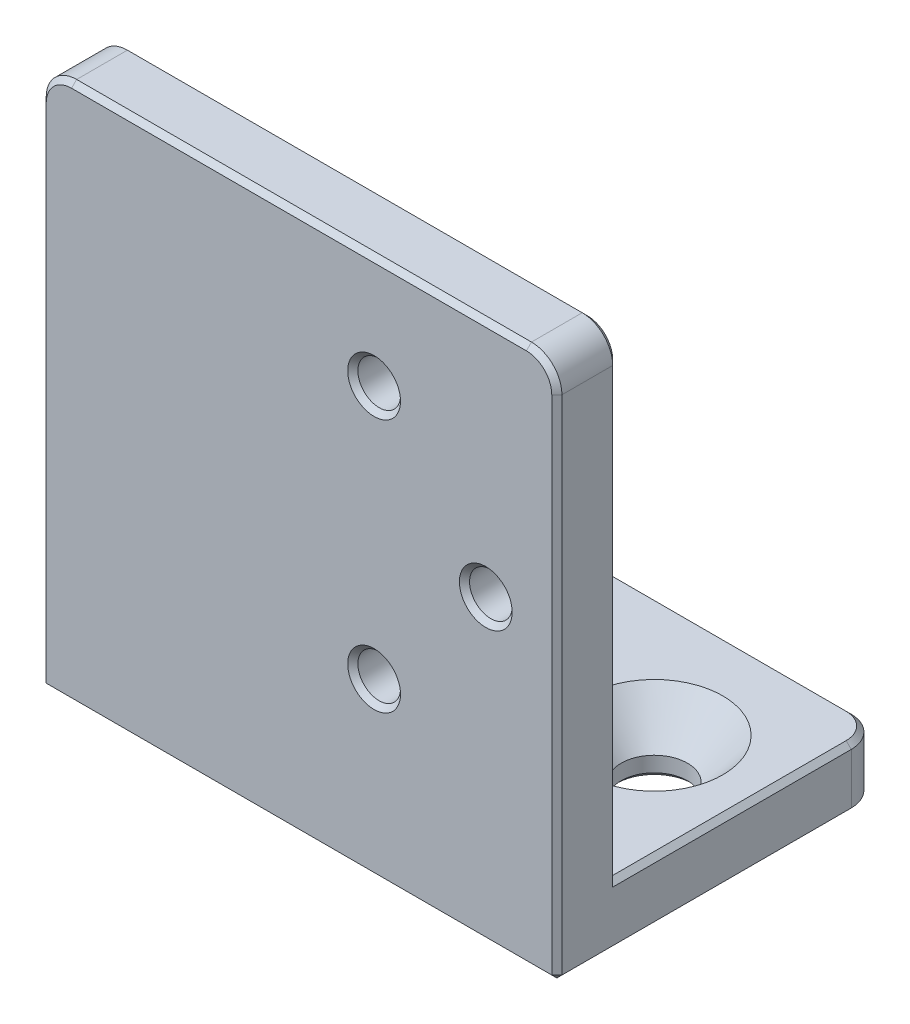
from build123d import *

# Parameters (mm, degrees)
SKETCH1_W                                    = 50.8
SKETCH1_H                                    = 53
SKETCH1_R                                    = 2.1
BOSS_EXTRUDE1_DEPTH                          = 6
SKETCH1_5_W                                  = 50.8
SKETCH1_5_H                                  = 6
BOSS_EXTRUDE2_DEPTH                          = 32
CSK_FOR_1_4_FLAT_HEAD_SOCKET_CAP_SCR_2_COUNT = 2
CSK_FOR_1_4_FLAT_HEAD_SOCKET_CAP_SCR_2_PITCH = 30
FILLET1_R                                    = 3
CHAMFER1_SIZE                                = 0.5


with BuildPart() as part:
    # Sketch1 → Boss-Extrude1 (new body)
    with BuildSketch(Plane.XY):
        with Locations((0, -3)):
            Rectangle(SKETCH1_W, SKETCH1_H)
        with Locations((7.4, -12.5)):
            Circle(SKETCH1_R, mode=Mode.SUBTRACT)
        with Locations((18.4, 0)):
            Circle(SKETCH1_R, mode=Mode.SUBTRACT)
        with Locations((7.4, 12.5)):
            Circle(SKETCH1_R, mode=Mode.SUBTRACT)
    extrude(amount=-BOSS_EXTRUDE1_DEPTH)

    # Sketch1_5 → Boss-Extrude2 (add)
    with BuildSketch(Plane.XY):
        with Locations((0, -26.5)):
            Rectangle(SKETCH1_5_W, SKETCH1_5_H)
    extrude(amount=-BOSS_EXTRUDE2_DEPTH)

    # Sketch4 → CSK for 1_4 Flat Head Socket Cap Screw1 (revolve, cut)
    with BuildSketch(Plane(origin=(-15, -23.5, -20), x_dir=(0, 0, 1), z_dir=(1, 0, 0))):
        Polygon((0, 0), (0, 6), (3.2639, 6), (3.2639, 4.003051983), (6.7437, 0), align=None)
    csk_for_1_4_flat_head_socket_cap_screw1 = revolve(axis=Axis((-15, -17.15, -20), (0, -1, 0)), mode=Mode.SUBTRACT)

    # CSK for 1_4 Flat Head Socket Cap Scr 2: CSK for 1_4 Flat Head Socket Cap Screw1 ×2
    with Locations(*[(i * CSK_FOR_1_4_FLAT_HEAD_SOCKET_CAP_SCR_2_PITCH, 0, 0) for i in range(1, CSK_FOR_1_4_FLAT_HEAD_SOCKET_CAP_SCR_2_COUNT)]):
        add(csk_for_1_4_flat_head_socket_cap_screw1, mode=Mode.SUBTRACT)

    # Fillet1
    fillet1_edges = [part.edges().sort_by_distance(p)[0] for p in [
        (25.4, 23.5, -3),
        (-25.4, 23.5, -3),
        (25.4, -26.5, -32),
        (-25.4, -26.5, -32),
    ]]
    fillet(fillet1_edges, radius=FILLET1_R)

    # Chamfer1
    chamfer1_edges = [part.edges().sort_by_distance(p)[0] for p in [
        (-24.521320344, 22.621320344, 0),
        (-25.4, -4.5, 0),
        (25.4, -4.5, 0),
        (24.521320344, 22.621320344, 0),
        (0, 23.5, 0),
        (16.3, 0, 0),
        (5.3, -12.5, 0),
        (5.3, 12.5, 0),
        (-25.4, -1.5, -6),
        (-24.521320344, 22.621320344, -6),
        (0, 23.5, -6),
        (24.521320344, 22.621320344, -6),
        (25.4, -1.5, -6),
        (16.3, 0, -6),
        (5.3, -12.5, -6),
        (5.3, 12.5, -6),
        (0, -29.5, 0),
        (-25.4, -23.5, -17.5),
        (25.4, -23.5, -17.5),
        (0, -23.5, -32),
        (-24.521320344, -23.5, -31.121320344),
        (24.521320344, -23.5, -31.121320344),
        (-25.4, -29.5, -14.5),
        (-24.521320344, -29.5, -31.121320344),
        (0, -29.5, -32),
        (24.521320344, -29.5, -31.121320344),
        (25.4, -29.5, -14.5),
        (-15, -29.5, -23.2639),
        (15, -29.5, -23.2639),
    ]]
    chamfer(chamfer1_edges, length=CHAMFER1_SIZE)


solid = part.part
